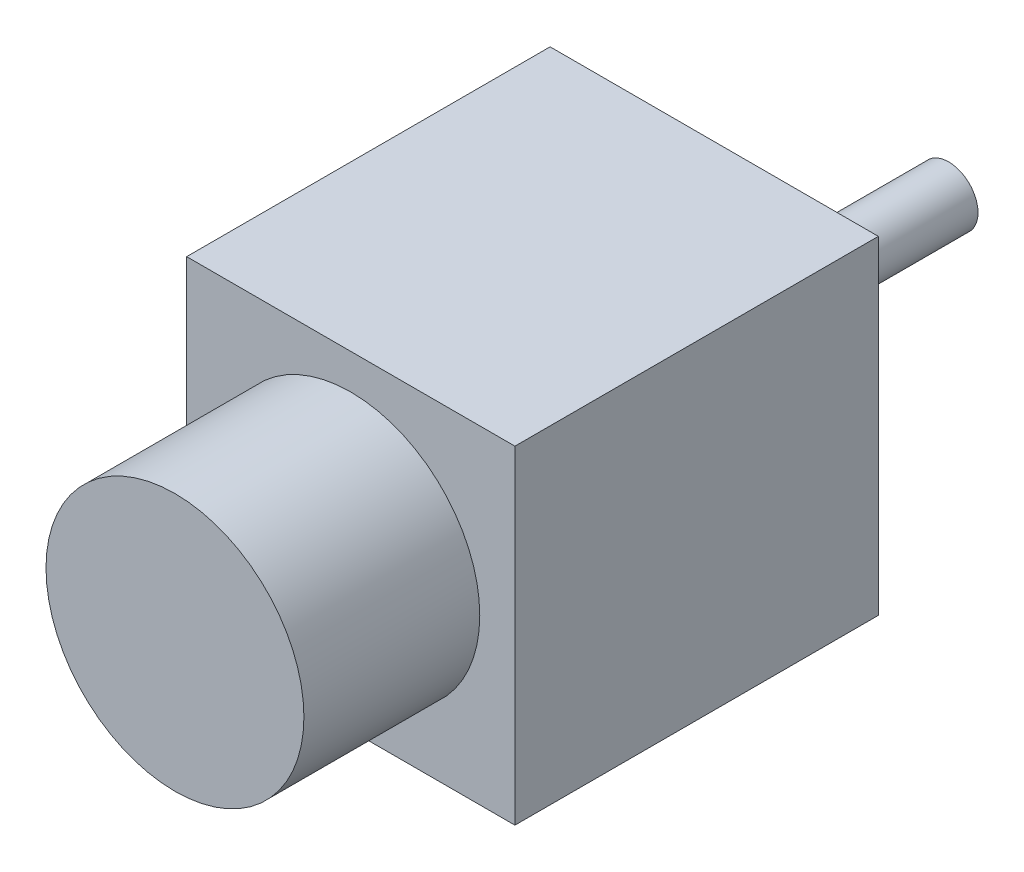
from build123d import *

# Parameters (mm, degrees)
SKETCH1_W           = 28
SKETCH1_H           = 28
BOSS_EXTRUDE1_DEPTH = 46
SKETCH2_W           = 28
SKETCH2_H           = 28
SKETCH2_R           = 11
CUT_EXTRUDE1_DEPTH  = 15
SKETCH3_R           = 2.5
BOSS_EXTRUDE2_DEPTH = 20


with BuildPart() as part:
    # Sketch1 → Boss-Extrude1 (new body)
    with BuildSketch(Plane.XY):
        with Locations((14, -14)):
            Rectangle(SKETCH1_W, SKETCH1_H)
    extrude(amount=BOSS_EXTRUDE1_DEPTH)

    # Sketch2 → Cut-Extrude1 (cut)
    with BuildSketch(Plane.XY.offset(46)):
        with Locations((14, -14)):
            Rectangle(SKETCH2_W, SKETCH2_H)
        with Locations((14, -14)):
            Circle(SKETCH2_R, mode=Mode.SUBTRACT)
    extrude(amount=-CUT_EXTRUDE1_DEPTH, mode=Mode.SUBTRACT)

    # Sketch3 → Boss-Extrude2 (add)
    with BuildSketch(Plane(origin=(0, 0, 0), x_dir=(-1, 0, 0), z_dir=(0, 0, -1))):
        with Locations((-14, -14)):
            Circle(SKETCH3_R)
    extrude(amount=BOSS_EXTRUDE2_DEPTH)


solid = part.part
